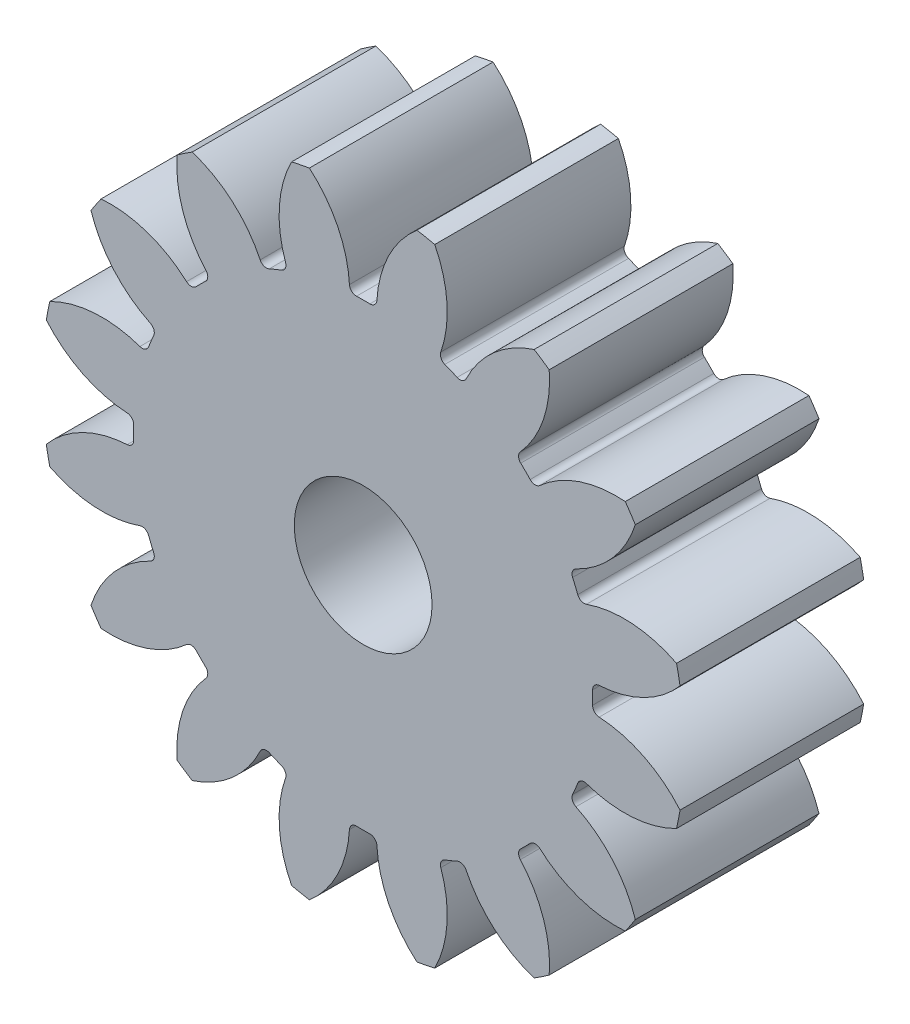
from build123d import *

# Parameters (mm, degrees)
SKETCH1_R           = 7
SKETCH1_R_2         = 1.5
BOSS_EXTRUDE1_DEPTH = 4
CUT_EXTRUDE2_DEPTH  = 5
CIRPATTERN2_COUNT   = 16


with BuildPart() as part:
    # Sketch1 → Boss-Extrude1 (new body)
    with BuildSketch(Plane.XY):
        Circle(SKETCH1_R)
        Circle(SKETCH1_R_2, mode=Mode.SUBTRACT)
    extrude(amount=BOSS_EXTRUDE1_DEPTH)

    # Sketch4 → Cut-Extrude2 (cut, through all)
    with BuildSketch(Plane.XY):
        with BuildLine():
            ThreePointArc((-0.144865992, 4.997900944), (0, 5), (0.144865992, 4.997900944))
            ThreePointArc((0.144865992, 4.997900944), (0.250687134, 5.037371727), (0.298978368, 5.139469785))
            ThreePointArc((0.298978368, 5.139469785), (0.554893378, 6.109748451), (1.171724109, 6.90123631))
            ThreePointArc((1.171724109, 6.90123631), (0, 7), (-1.171724109, 6.90123631))
            ThreePointArc((-1.171724109, 6.90123631), (-0.554893378, 6.109748451), (-0.298978368, 5.139469785))
            ThreePointArc((-0.298978368, 5.139469785), (-0.250687134, 5.037371727), (-0.144865992, 4.997900944))
        make_face()
    cut_extrude2 = extrude(amount=CUT_EXTRUDE2_DEPTH, mode=Mode.SUBTRACT)

    # CirPattern2: Cut-Extrude2 ×16 about axis
    cirpattern2_axis = Axis((0, 0, 0), (0, 0, 1))
    for i in range(1, CIRPATTERN2_COUNT):
        add(cut_extrude2.rotate(cirpattern2_axis, i * 360 / CIRPATTERN2_COUNT), mode=Mode.SUBTRACT)


solid = part.part
